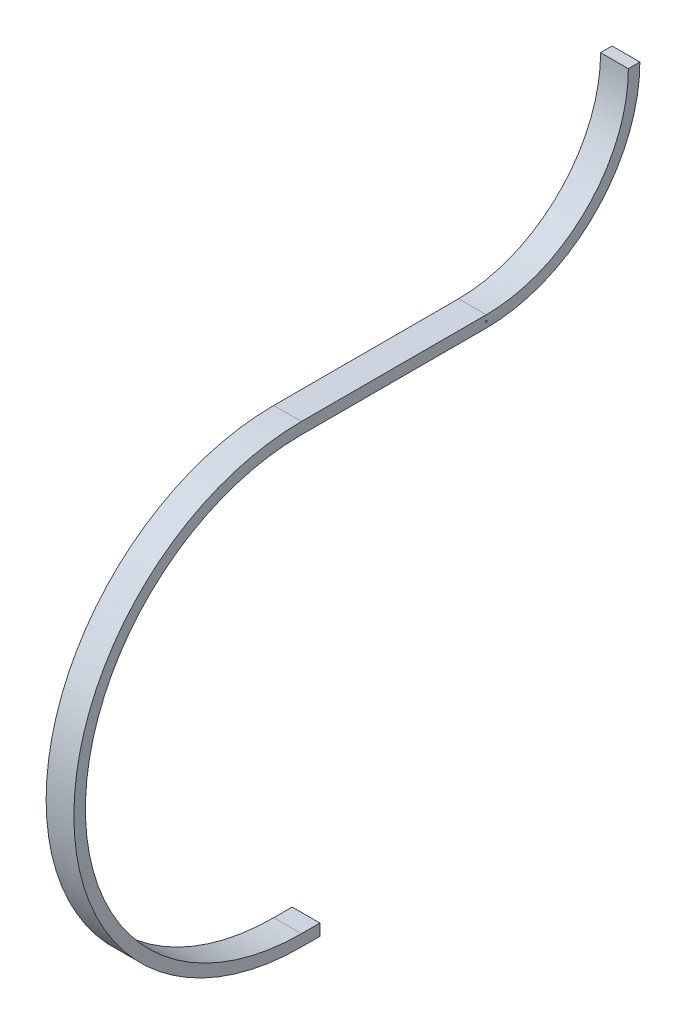
from build123d import *

# Parameters (mm, degrees)
SKETCH1_W                    = 19.05
SKETCH1_H                    = 7.9248
SKETCH3_W                    = 12.7
SKETCH3_H                    = 7.9248
BOSS_EXTRUDE1_DEPTH          = 19.05
F_56_0_0465_DIAMETER_HOLE1_D = 1.1811


with BuildPart() as part:
    # Sweep1: sweep along a path in Sketch2
    with BuildLine(Plane(origin=(0, 0, 0), x_dir=(0, 0, -1), z_dir=(1, 0, 0))) as sweep1_path:
        ThreePointArc((0, 0), (-152.4, 152.4), (0, 304.8))
        Line((0, 304.8), (127, 304.8))
        ThreePointArc((127, 304.8), (198.842048969, 334.557951031), (228.6, 406.4))
    # Sketch1 → Sweep1 (sweep)
    with BuildSketch(Plane.XY):
        Rectangle(SKETCH1_W, SKETCH1_H)
    sweep(path=sweep1_path.line)

    # Sketch3 → Boss-Extrude1 (add)
    with BuildSketch(Plane(origin=(9.525, 0, 0), x_dir=(0, 0, -1), z_dir=(1, 0, 0))):
        with Locations((6.35, 0)):
            Rectangle(SKETCH3_W, SKETCH3_H)
    extrude(amount=-BOSS_EXTRUDE1_DEPTH)

    # #56 (0.0465) Diameter Hole1 (through all)
    with Locations(Plane(origin=(9.525, 0, 0), x_dir=(0, 0, -1), z_dir=(1, 0, 0))):
        with Locations((127, 304.8)):
            Hole(F_56_0_0465_DIAMETER_HOLE1_D / 2)


solid = part.part
